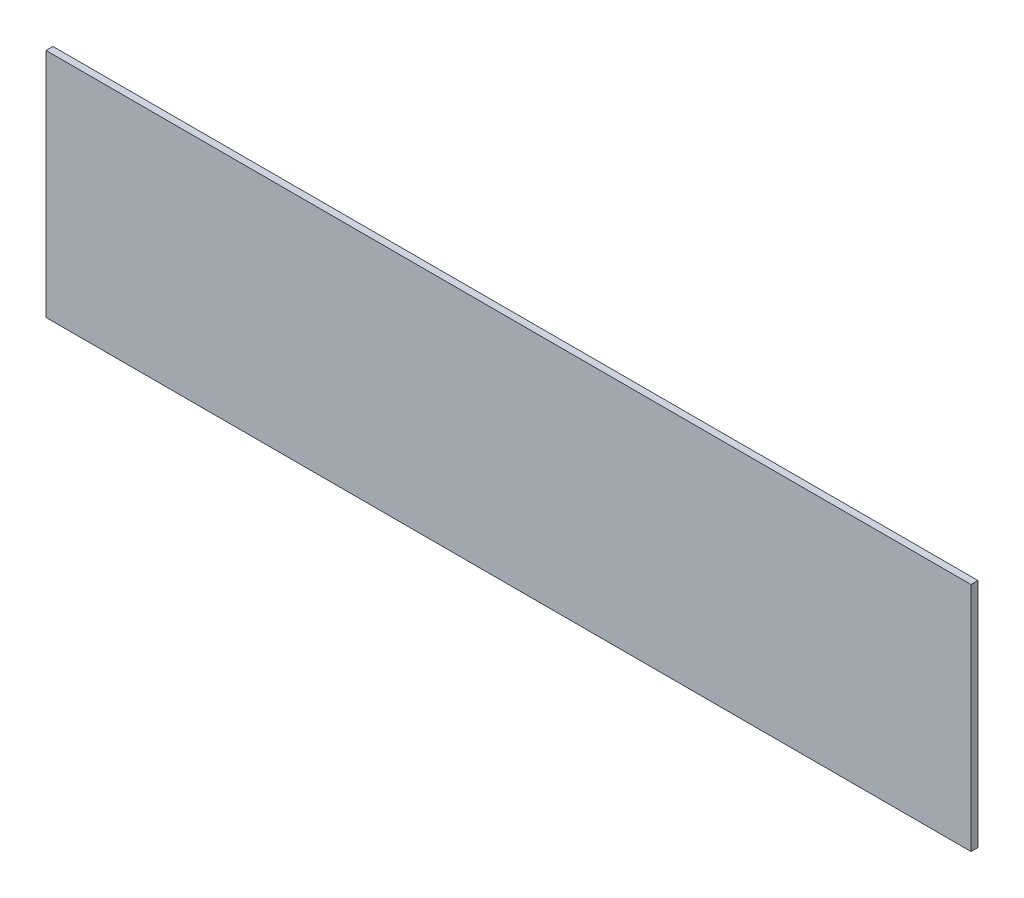
from build123d import *

# Parameters (mm, degrees)
SKETCH1_W           = 408
SKETCH1_H           = 100
BOSS_EXTRUDE1_DEPTH = 3
SKETCH3_W           = 8
SKETCH3_H           = 100
CUT_EXTRUDE2_DEPTH  = 10


with BuildPart() as part:
    # Sketch1 → Boss-Extrude1 (new body)
    with BuildSketch(Plane.XY):
        with Locations((204, 50)):
            Rectangle(SKETCH1_W, SKETCH1_H)
    extrude(amount=BOSS_EXTRUDE1_DEPTH)

    # Sketch3 → Cut-Extrude2 (cut)
    with BuildSketch(Plane(origin=(0, 0, 0), x_dir=(-1, 0, 0), z_dir=(0, 0, -1))):
        with Locations((-4, 50)):
            Rectangle(SKETCH3_W, SKETCH3_H)
    extrude(amount=-CUT_EXTRUDE2_DEPTH, mode=Mode.SUBTRACT)


solid = part.part
